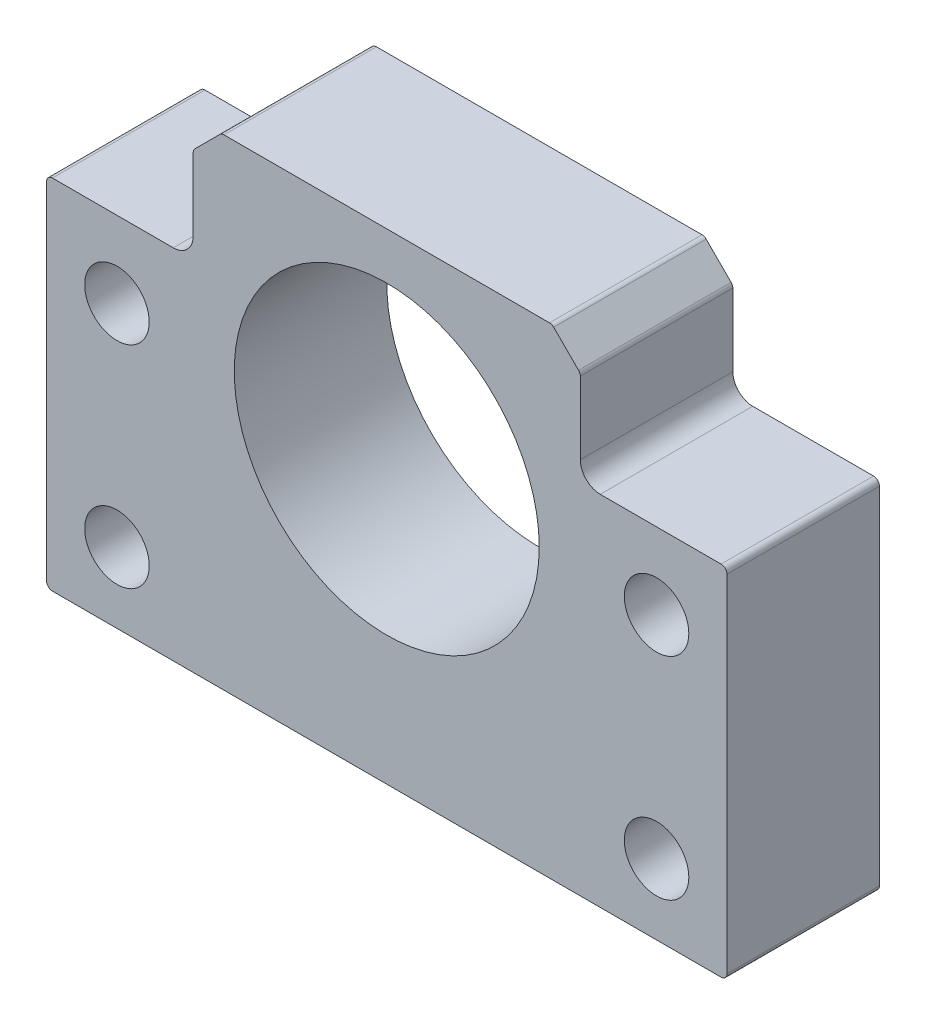
from build123d import *

# Parameters (mm, degrees)
SKETCH1_R           = 2.75
SKETCH1_R_2         = 13
BOSS_EXTRUDE1_DEPTH = 13
FILLET1_R           = 1.7
FILLET2_R           = 0.5


with BuildPart() as part:
    # Sketch1 → Boss-Extrude1 (new body)
    with BuildSketch(Plane.XY):
        Polygon((40.027969698, 14.696983914), (27.527969698, 14.696983914), (27.527969698, 22.782770351), (25.113756136, 25.196983914), (-3.057816739, 25.196983914), (-5.472030302, 22.782770351), (-5.472030302, 14.696983914), (-17.972030302, 14.696983914), (-17.972030302, -15.803016086), (40.027969698, -15.803016086), align=None)
        with Locations((34.027969698, 8.196983914)):
            Circle(SKETCH1_R, mode=Mode.SUBTRACT)
        with Locations((34.027969698, -9.803016086)):
            Circle(SKETCH1_R, mode=Mode.SUBTRACT)
        with Locations((-11.972030302, -9.803016086)):
            Circle(SKETCH1_R, mode=Mode.SUBTRACT)
        with Locations((-11.972030302, 8.196983914)):
            Circle(SKETCH1_R, mode=Mode.SUBTRACT)
        with Locations((11.027969698, 8.196983914)):
            Circle(SKETCH1_R_2, mode=Mode.SUBTRACT)
    extrude(amount=BOSS_EXTRUDE1_DEPTH)

    # Fillet1
    fillet1_edges = [part.edges().sort_by_distance(p)[0] for p in [
        (-5.472030302, 14.696983914, 6.5),
        (27.527969698, 14.696983914, 6.5),
    ]]
    fillet(fillet1_edges, radius=FILLET1_R)

    # Fillet2
    fillet2_edges = [part.edges().sort_by_distance(p)[0] for p in [
        (40.027969698, -15.803016086, 6.5),
        (-17.972030302, -15.803016086, 6.5),
        (-17.972030302, 14.696983914, 6.5),
        (-5.472030302, 22.782770351, 6.5),
        (-3.057816739, 25.196983914, 6.5),
        (25.113756136, 25.196983914, 6.5),
        (27.527969698, 22.782770351, 6.5),
        (40.027969698, 14.696983914, 6.5),
    ]]
    fillet(fillet2_edges, radius=FILLET2_R)


solid = part.part
